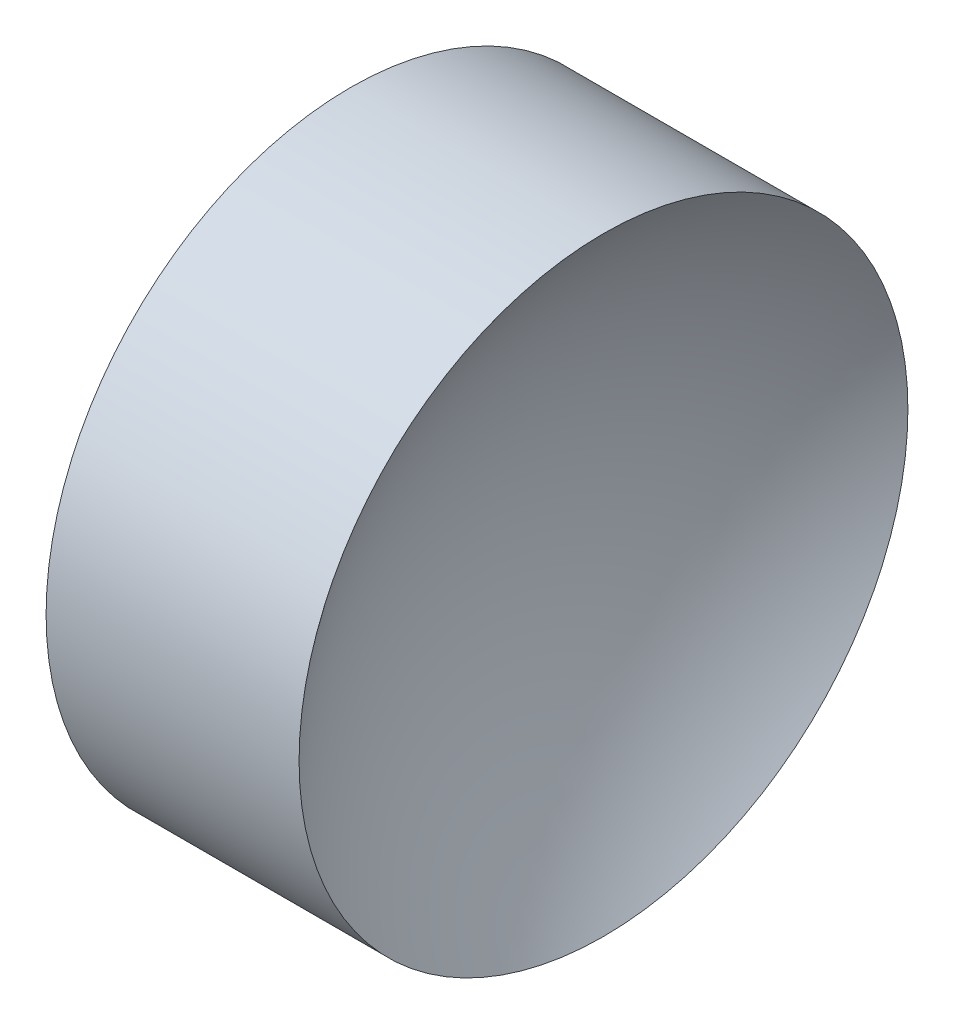
from build123d import *


with BuildPart() as part:
    # 草图1 → 旋转1 (revolve)
    with BuildSketch(Plane.XY, mode=Mode.PRIVATE) as revolve_1_sk:
        with BuildLine():
            Line((366.562400986, 112.592117064), (366.562400986, 118.842117064))
            Line((366.562400986, 118.842117064), (371.756153488, 118.842117064))
            ThreePointArc((371.756153488, 118.842117064), (370.126764415, 115.904029278), (369.562400986, 112.592117064))
            Line((369.562400986, 112.592117064), (366.562400986, 112.592117064))
        make_face()
    revolve(revolve_1_sk.sketch.rotate(Axis((363.508644719, 112.592117064, 0), (1, 0, 0)), 180), axis=Axis((363.508644719, 112.592117064, 0), (1, 0, 0)))  # turned: the seam where the file's is


solid = part.part
